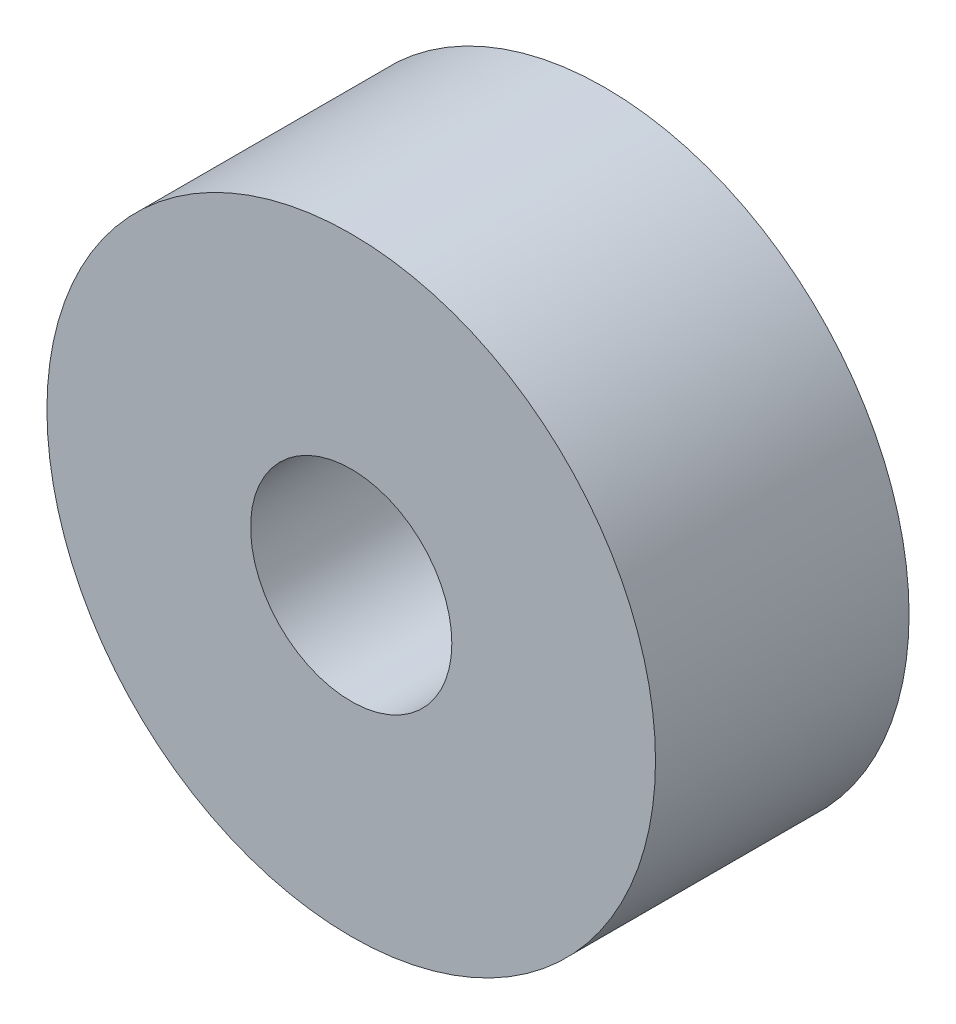
from build123d import *

# Parameters (mm, degrees)
SKETCH1_R           = 4.8
SKETCH1_R_2         = 1.5875
BOSS_EXTRUDE1_DEPTH = 4


with BuildPart() as part:
    # Sketch1 → Boss-Extrude1 (new body)
    with BuildSketch(Plane.XY):
        Circle(SKETCH1_R)
        Circle(SKETCH1_R_2, mode=Mode.SUBTRACT)
    extrude(amount=BOSS_EXTRUDE1_DEPTH)


solid = part.part
